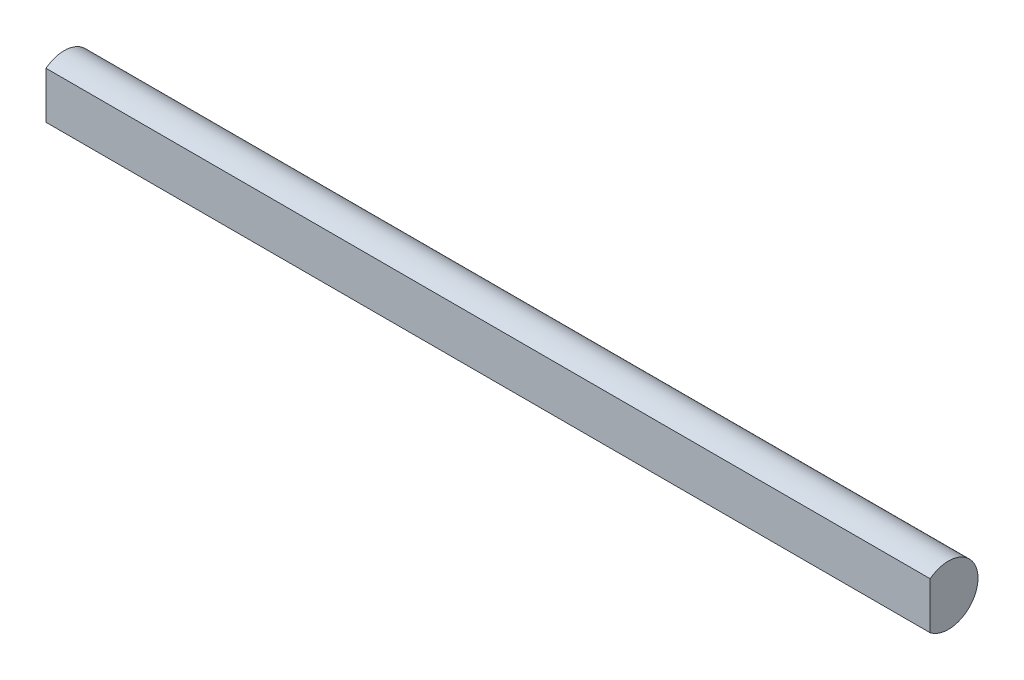
from build123d import *

# Parameters (mm, degrees)
BOSS_EXTRUDE1_DEPTH = 85


with BuildPart() as part:
    # Sketch1 → Boss-Extrude1 (new body)
    with BuildSketch(Plane(origin=(0, 0, 0), x_dir=(0, 0, -1), z_dir=(1, 0, 0))):
        with BuildLine():
            Line((-1.749285568, 2.25), (-1.749285568, -2.25))
            ThreePointArc((-1.749285568, -2.25), (2.85, 0), (-1.749285568, 2.25))
        make_face()
    extrude(amount=BOSS_EXTRUDE1_DEPTH)


solid = part.part
